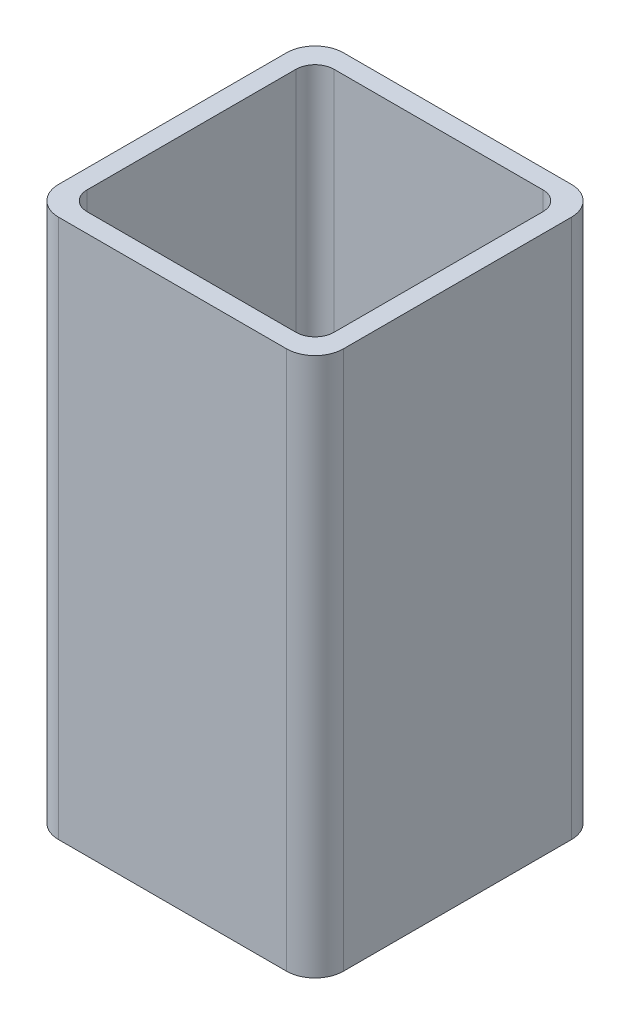
from build123d import *

# Parameters (mm, degrees)
EXTRUDE_1_DEPTH = 56.773811


with BuildPart() as part:
    # Эскиз1 → Бобышка-Вытянуть1 (new body)
    with BuildSketch(Plane(origin=(0, 0, 0), x_dir=(1, 0, 0), z_dir=(0, 1, 0))):
        with BuildLine():
            Line((-27, 15), (-3, 15))
            ThreePointArc((-3, 15), (-0.878679656, 14.121320344), (0, 12))
            Line((0, 12), (0, -12))
            ThreePointArc((0, -12), (-0.878679656, -14.121320344), (-3, -15))
            Line((-3, -15), (-27, -15))
            ThreePointArc((-27, -15), (-29.121320344, -14.121320344), (-30, -12))
            Line((-30, -12), (-30, 12))
            ThreePointArc((-30, 12), (-29.121320344, 14.121320344), (-27, 15))
        make_face()
        with BuildLine():
            Line((-26, 13), (-4, 13))
            ThreePointArc((-4, 13), (-2.585786438, 12.414213562), (-2, 11))
            Line((-2, 11), (-2, -11))
            ThreePointArc((-2, -11), (-2.585786438, -12.414213562), (-4, -13))
            Line((-4, -13), (-26, -13))
            ThreePointArc((-26, -13), (-27.414213562, -12.414213562), (-28, -11))
            Line((-28, -11), (-28, 11))
            ThreePointArc((-28, 11), (-27.414213562, 12.414213562), (-26, 13))
        make_face(mode=Mode.SUBTRACT)
    extrude(amount=-EXTRUDE_1_DEPTH)


solid = part.part
